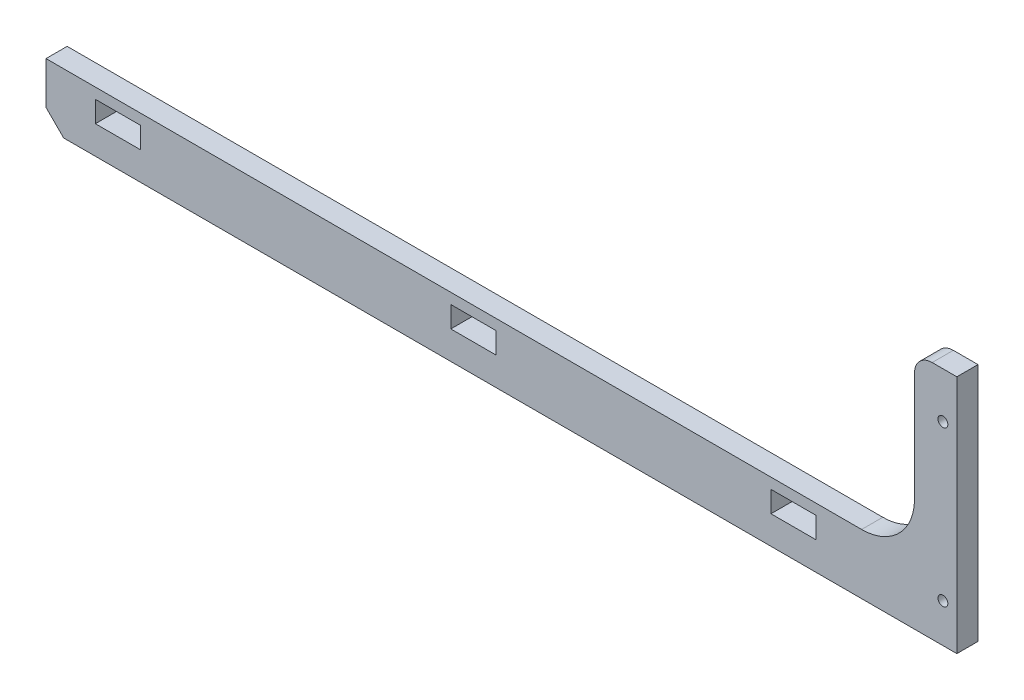
from build123d import *

# Parameters (mm, degrees)
SKETCH_1_R      = 1.4
SKETCH_1_W      = 12.8
SKETCH_1_H      = 6
EXTRUDE_1_DEPTH = 6


with BuildPart() as part:
    # Эскиз1 → Бобышка-Вытянуть1 (new body)
    with BuildSketch(Plane.XY):
        with BuildLine():
            Line((-167.182566644, 6), (64.127433356, 6))
            ThreePointArc((64.127433356, 6), (74.734035074, 10.393398282), (79.127433356, 21))
            Line((79.127433356, 21), (79.127433356, 44))
            Line((79.127433356, 44), (79.127433356, 52))
            ThreePointArc((79.127433356, 52), (80.59189945, 55.535533906), (84.127433356, 57))
            Line((84.127433356, 57), (91.127433356, 57))
            Line((91.127433356, 57), (91.127433356, 49))
            Line((91.127433356, 49), (91.127433356, 6))
            Line((91.127433356, 6), (91.127433356, -11))
            Line((91.127433356, -11), (-162.182566644, -11))
            Line((-162.182566644, -11), (-167.182566644, -6))
            Line((-167.182566644, -6), (-167.182566644, 6))
        make_face()
        with Locations((87.177433356, 0)):
            Circle(SKETCH_1_R, mode=Mode.SUBTRACT)
        with Locations((87.177433356, 44)):
            Circle(SKETCH_1_R, mode=Mode.SUBTRACT)
        with Locations((44.817433356, 0)):
            Rectangle(SKETCH_1_W, SKETCH_1_H, mode=Mode.SUBTRACT)
        with Locations((-45.982566644, 0)):
            Rectangle(SKETCH_1_W, SKETCH_1_H, mode=Mode.SUBTRACT)
        with Locations((-146.782566644, 0)):
            Rectangle(SKETCH_1_W, SKETCH_1_H, mode=Mode.SUBTRACT)
    extrude(amount=EXTRUDE_1_DEPTH)


solid = part.part
